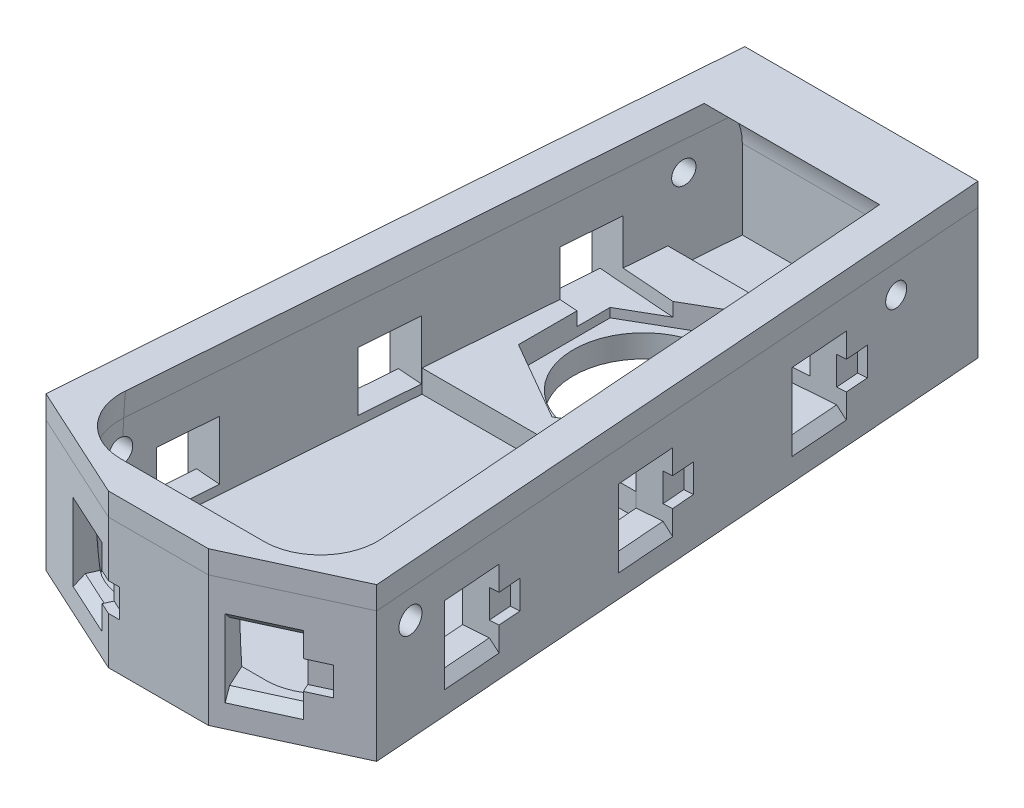
from build123d import *

# Parameters (mm, degrees)
SKETCH1_W               = 29.4
SKETCH1_H               = 62
BOSS_EXTRUDE1_DEPTH     = 11.5
CUT_EXTRUDE2_DEPTH      = 11.7
CUT_EXTRUDE2_DEPTH_BACK = 11.7
BOSS_EXTRUDE3_DEPTH     = 11.5
SKETCH4_R               = 1
CUT_EXTRUDE3_DEPTH      = 15.7
CUT_EXTRUDE3_DEPTH_BACK = 15.7
FILLET1_R               = 5
SKETCH7_W               = 29.4
SKETCH7_H               = 62
SKETCH7_R               = 6.2
BOSS_EXTRUDE4_DEPTH     = 2
BOSS_EXTRUDE5_DEPTH     = 2
SKETCH9_R               = 1.1
CUT_EXTRUDE4_DEPTH      = 30.4000001
CUT_EXTRUDE7_DEPTH      = 14.5
CUT_EXTRUDE5_DEPTH      = 14.5
SKETCH13_W              = 5.2
SKETCH13_H              = 5.2
CUT_EXTRUDE6_DEPTH      = 10
SKETCH16_W              = 5.2
SKETCH16_H              = 5.2
CUT_EXTRUDE8_DEPTH      = 10
CHAMFER1_SIZE           = 0.8
SKETCH17_W              = 2
SKETCH17_H              = 2.5
CUT_EXTRUDE9_DEPTH      = 0.8
SKETCH18_W              = 2
SKETCH18_H              = 2.5
CUT_EXTRUDE10_DEPTH     = 0.8
SKETCH19_W              = 2
SKETCH19_H              = 2.5
CUT_EXTRUDE11_DEPTH     = 0.8
SKETCH20_W              = 2
SKETCH20_H              = 2.5
CUT_EXTRUDE12_DEPTH     = 0.8


with BuildPart() as part:
    # Sketch1 → Boss-Extrude1 (new body)
    with BuildSketch(Plane(origin=(0, 0, 0), x_dir=(1, 0, 0), z_dir=(0, 1, 0))):
        Rectangle(SKETCH1_W, SKETCH1_H)
    extrude(amount=-BOSS_EXTRUDE1_DEPTH)

    # Sketch3 → Cut-Extrude2 (cut, two sides)
    with BuildSketch(Plane(origin=(0, 0, 0), x_dir=(0, 0, -1), z_dir=(1, 0, 0))) as cut_extrude2_sk:
        with BuildLine():
            Line((28, -4.5), (28, -55.672746653))
            ThreePointArc((28, -55.672746653), (-13.036772483, -40.949778052), (-28, 0))
            Line((-28, 0), (-27.698836685, 0))
            Line((-27.698836685, 0), (23.2, 0))
            Line((23.2, 0), (24.870329309, 0))
            ThreePointArc((24.870329309, 0), (27.140658618, -1.759341382), (28, -4.5))
        make_face()
    extrude(amount=CUT_EXTRUDE2_DEPTH, mode=Mode.SUBTRACT)
    extrude(cut_extrude2_sk.sketch, amount=-CUT_EXTRUDE2_DEPTH_BACK, mode=Mode.SUBTRACT)

    # Sketch6 → Boss-Extrude3 (add)
    with BuildSketch(Plane(origin=(0, 0, 0), x_dir=(1, 0, 0), z_dir=(0, 1, 0))):
        Polygon((-11.7, 28), (-11.7, -28), (-7.5, 28), align=None)
        Polygon((11.7, 28), (7.5, 28), (11.7, -28), align=None)
    extrude(amount=-BOSS_EXTRUDE3_DEPTH)

    # Sketch4 → Cut-Extrude3 (cut, two sides)
    with BuildSketch(Plane(origin=(0, 0, 0), x_dir=(0, 0, -1), z_dir=(1, 0, 0))) as cut_extrude3_sk:
        with Locations((23.2, -4.5)):
            Circle(SKETCH4_R)
    extrude(amount=CUT_EXTRUDE3_DEPTH, mode=Mode.SUBTRACT)
    extrude(cut_extrude3_sk.sketch, amount=-CUT_EXTRUDE3_DEPTH_BACK, mode=Mode.SUBTRACT)

    # Fillet1
    fillet1_edges = [part.edges().sort_by_distance(p)[0] for p in [
        (-11.7, -4.5, 28.197373474),
        (11.7, -4.5, 28.197373474),
    ]]
    fillet(fillet1_edges, radius=FILLET1_R)

    # Sketch7 → Boss-Extrude4 (add)
    with BuildSketch(Plane(origin=(0, -11.5, 0), x_dir=(-1, 0, 0), z_dir=(0, -1, 0))):
        Rectangle(SKETCH7_W, SKETCH7_H)
        with Locations((0, 11.8)):
            Circle(SKETCH7_R, mode=Mode.SUBTRACT)
    extrude(amount=BOSS_EXTRUDE4_DEPTH)

    # Sketch8 → Boss-Extrude5 (add)
    with BuildSketch(Plane(origin=(0, -11.5, 0), x_dir=(1, 0, 0), z_dir=(0, 1, 0))):
        Polygon((-9.471217783, 1.717096231), (9.471217783, 1.717096231), (7.958782217, 21.882903769), (-7.958782217, 21.882903769), align=None)
        Polygon((7, 7.758548116), (7, 15.841451884), (0, 19.882903769), (-7, 15.841451884), (-7, 7.758548116), (0, 3.717096231), align=None, mode=Mode.SUBTRACT)
    extrude(amount=BOSS_EXTRUDE5_DEPTH)

    # Sketch9 → Cut-Extrude4 (cut, through all)
    with BuildSketch(Plane.ZY.offset(14.7)):
        with Locations((23.109022166, -4.452691104)):
            Circle(SKETCH9_R)
    extrude(amount=-CUT_EXTRUDE4_DEPTH, mode=Mode.SUBTRACT)

    # Sketch15 → Cut-Extrude7 (cut, through all)
    with BuildSketch(Plane(origin=(0, 0, 0), x_dir=(1, 0, 0), z_dir=(0, 1, 0))):
        Polygon((-10.283425668, 31), (-14.7, -27.88765776), (-14.7, 31), align=None)
        Polygon((10.283425668, 31), (14.7, -27.88765776), (14.7, 31), align=None)
    extrude(amount=-CUT_EXTRUDE7_DEPTH, mode=Mode.SUBTRACT)

    # Sketch12 → Cut-Extrude5 (cut, through all)
    with BuildSketch(Plane(origin=(0, 0, 0), x_dir=(1, 0, 0), z_dir=(0, 1, 0))):
        Polygon((-14.7, -26.273466426), (-4.409179648, -31), (-14.7, -31), align=None)
        Polygon((14.7, -31), (14.7, -26.273466426), (4.409179648, -31), align=None)
    extrude(amount=-CUT_EXTRUDE5_DEPTH, mode=Mode.SUBTRACT)

    # Sketch13 → Cut-Extrude6 (cut)
    with BuildSketch(Plane(origin=(-12.525927383, 0, 27.272009483), x_dir=(0.908733156, 0, 0.417377588), z_dir=(-0.417377588, 0, 0.908733156))):
        with Locations((5.214473387, -8.1)):
            Rectangle(SKETCH13_W, SKETCH13_H)
    cut_extrude6 = extrude(amount=-CUT_EXTRUDE6_DEPTH, mode=Mode.SUBTRACT)

    # Sketch16 → Cut-Extrude8 (cut)
    with BuildSketch(Plane(origin=(-12.537899981, 0, -0.940342499), x_dir=(-0.074789948, 0, 0.99719931), z_dir=(-0.99719931, 0, -0.074789948))):
        with Locations((18.24414415, -8.1)):
            Rectangle(SKETCH16_W, SKETCH16_H)
        with Locations((1.64414415, -8.1)):
            Rectangle(SKETCH16_W, SKETCH16_H)
        with Locations((-14.95585585, -8.1)):
            Rectangle(SKETCH16_W, SKETCH16_H)
    cut_extrude8 = extrude(amount=-CUT_EXTRUDE8_DEPTH, mode=Mode.SUBTRACT)

    # Mirror1: Cut-Extrude6, Cut-Extrude8 across plane
    add(cut_extrude6.mirror(Plane(origin=(0, 0, 0), x_dir=(0, 0, 1), z_dir=(1, 0, 0))), mode=Mode.SUBTRACT)
    add(cut_extrude8.mirror(Plane(origin=(0, 0, 0), x_dir=(0, 0, 1), z_dir=(1, 0, 0))), mode=Mode.SUBTRACT)

    # Chamfer1
    chamfer1_edges = [part.edges().sort_by_distance(p)[0] for p in [
        (-7.787362524, -10.7, 29.448413806),
        (-7.787362524, -5.5, 29.448413806),
        (-13.902378577, -5.5, 17.252705457),
        (-13.902378577, -10.7, 17.252705457),
        (-12.660865436, -5.5, 0.699196913),
        (-12.660865436, -10.7, 0.699196913),
        (-11.419352296, -5.5, -15.854311631),
        (-11.419352296, -10.7, -15.854311631),
        (7.787362524, -10.7, 29.448413806),
        (7.787362524, -5.5, 29.448413806),
        (13.902378577, -5.5, 17.252705457),
        (13.902378577, -10.7, 17.252705457),
        (12.660865436, -5.5, 0.699196913),
        (12.660865436, -10.7, 0.699196913),
        (11.419352296, -5.5, -15.854311631),
        (11.419352296, -10.7, -15.854311631),
    ]]
    chamfer(chamfer1_edges, length=CHAMFER1_SIZE)

    # Sketch17 → Cut-Extrude9 (cut)
    with BuildSketch(Plane(origin=(-12.537899981, 0, -0.940342499), x_dir=(-0.074789948, 0, 0.99719931), z_dir=(-0.99719931, 0, -0.074789948))):
        with Locations((-11.35585585, -8.1)):
            Rectangle(SKETCH17_W, SKETCH17_H)
        with Locations((5.24414415, -8.1)):
            Rectangle(SKETCH17_W, SKETCH17_H)
        with Locations((21.84414415, -8.1)):
            Rectangle(SKETCH17_W, SKETCH17_H)
    extrude(amount=-CUT_EXTRUDE9_DEPTH, mode=Mode.SUBTRACT)

    # Sketch18 → Cut-Extrude10 (cut)
    with BuildSketch(Plane(origin=(-12.525927383, 0, 27.272009483), x_dir=(0.908733156, 0, 0.417377588), z_dir=(-0.417377588, 0, 0.908733156))):
        with Locations((8.814473387, -8.1)):
            Rectangle(SKETCH18_W, SKETCH18_H)
    extrude(amount=-CUT_EXTRUDE10_DEPTH, mode=Mode.SUBTRACT)

    # Sketch19 → Cut-Extrude11 (cut)
    with BuildSketch(Plane(origin=(12.525927383, 0, 27.272009483), x_dir=(0.908733156, 0, -0.417377588), z_dir=(0.417377588, 0, 0.908733156))):
        with Locations((-1.614473387, -8.1)):
            Rectangle(SKETCH19_W, SKETCH19_H)
    extrude(amount=-CUT_EXTRUDE11_DEPTH, mode=Mode.SUBTRACT)

    # Sketch20 → Cut-Extrude12 (cut)
    with BuildSketch(Plane(origin=(12.537899981, 0, -0.940342499), x_dir=(-0.074789948, 0, -0.99719931), z_dir=(0.99719931, 0, -0.074789948))):
        with Locations((-14.64414415, -8.1)):
            Rectangle(SKETCH20_W, SKETCH20_H)
        with Locations((1.95585585, -8.1)):
            Rectangle(SKETCH20_W, SKETCH20_H)
        with Locations((18.55585585, -8.1)):
            Rectangle(SKETCH20_W, SKETCH20_H)
    extrude(amount=-CUT_EXTRUDE12_DEPTH, mode=Mode.SUBTRACT)


with BuildPart() as body_2:
    # Split1: the piece on the far side of the plane
    add(part.part)
    split(bisect_by=Plane.ZX.offset(-2), keep=Keep.BOTTOM)


with BuildPart() as part_1:
    add(part.part)

    # Split1
    split(bisect_by=Plane.ZX.offset(-2), keep=Keep.TOP)


solid = Compound([body_2.part, part_1.part])
